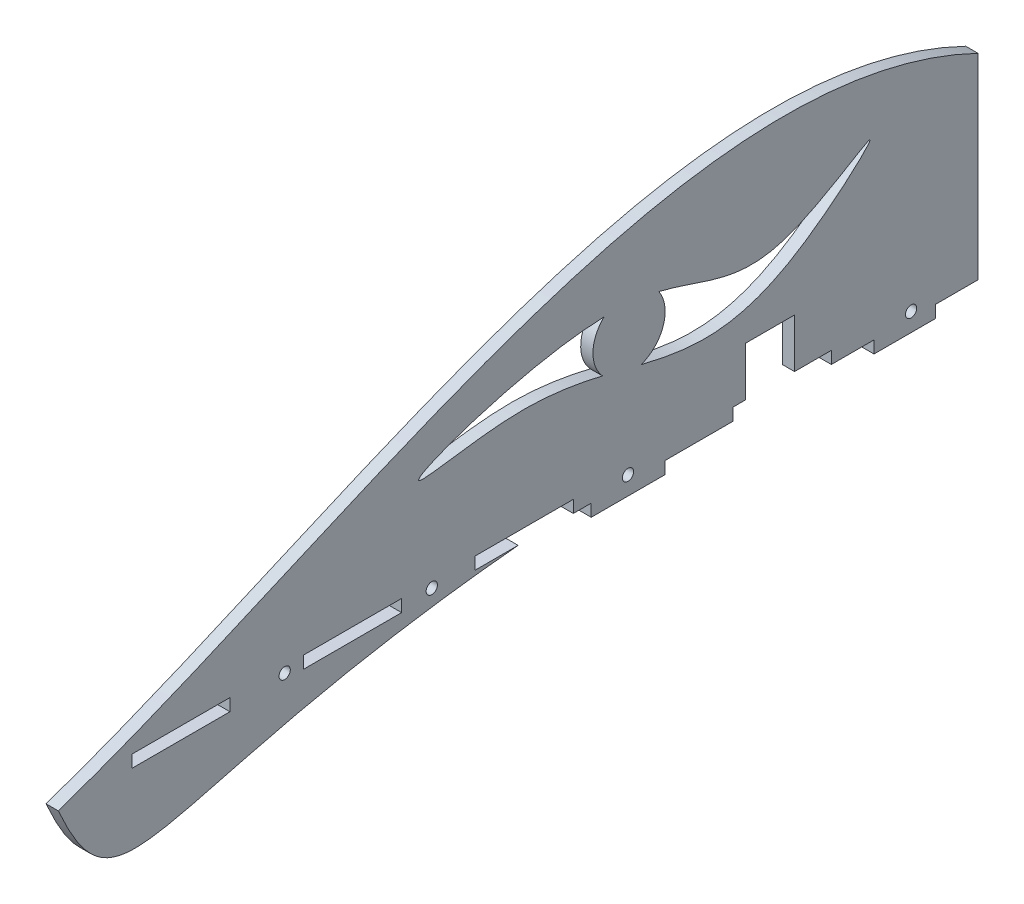
from build123d import *

# Parameters (mm, degrees)
BOSS_EXTRUDE1_DEPTH = 3.175
SKETCH2_R           = 1.4605
SKETCH2_W           = 25.4
SKETCH2_H           = 3.175
CUT_EXTRUDE1_DEPTH  = 6.35
BOSS_EXTRUDE3_DEPTH = 3.175
CUT_EXTRUDE2_DEPTH  = 3.175
SKETCH5_R           = 9.342587617
BOSS_EXTRUDE4_DEPTH = 3.175


with BuildPart() as part:
    # Sketch1 → Boss-Extrude1 (new body)
    with BuildSketch(Plane(origin=(0, 0, 0), x_dir=(0, 0, -1), z_dir=(1, 0, 0))):
        with BuildLine():
            Line((119.0625, 0), (238.125, 0))
            Line((238.125, 0), (238.125, 50.8))
            add(Edge.make_bspline(
                [(0, 0), (76.859833449, 26.070949446), (164.07477212, 86.623684005), (238.125, 50.8)],
                knots=[0, 0, 0, 0, 1, 1, 1, 1], degree=3))
            add(Edge.make_bspline(
                [(0, 0), (16.104921012, -36.272981342), (24.443498776, -9.039116005), (119.0625, 0)],
                knots=[0, 0, 0, 0, 1, 1, 1, 1], degree=3))
        make_face()
    extrude(amount=BOSS_EXTRUDE1_DEPTH)

    # Sketch2 → Cut-Extrude1 (cut)
    with BuildSketch(Plane(origin=(3.175, 0, 0), x_dir=(0, 0, -1), z_dir=(1, 0, 0))):
        Polygon((177.927, 15.875), (177.927, 3.175), (183.007, 3.175), (190.627, 3.175), (190.627, 15.875), (183.007, 15.875), align=None)
        Polygon((174.752, 3.175), (174.752, 0), (200.152, 0), (200.152, 3.175), (195.707, 3.175), (190.627, 3.175), (183.007, 3.175), (177.927, 3.175), align=None)
        with Locations((220.7895, 1.5875)):
            Circle(SKETCH2_R)
        Polygon((107.95, 3.175), (107.95, 0), (119.0625, 0), (133.35, 0), (133.35, 3.175), align=None)
        with Locations((76.2, 1.5875)):
            Rectangle(SKETCH2_W, SKETCH2_H)
        with Locations((31.75, 1.5875)):
            Rectangle(SKETCH2_W, SKETCH2_H)
        with Locations((58.6105, 1.5875)):
            Circle(SKETCH2_R)
        with Locations((147.5105, 1.5875)):
            Circle(SKETCH2_R)
        with Locations((96.7105, 1.5875)):
            Circle(SKETCH2_R)
    extrude(amount=-CUT_EXTRUDE1_DEPTH, mode=Mode.SUBTRACT)

    # Sketch3 → Boss-Extrude3 (add)
    with BuildSketch(Plane(origin=(3.175, 0, 0), x_dir=(0, 0, -1), z_dir=(1, 0, 0))):
        Polygon((137.98202267, -3.175), (137.98202267, 0), (137.98202267, 0.026209123), (157.03202267, 0.026209123), (157.03202267, 0), (157.03202267, -3.175), align=None)
        Polygon((211.201, -3.175), (227.076, -3.175), (227.076, 0), (227.076, 0.026209123), (208.026, 0.026209123), (211.201, 0), align=None)
    extrude(amount=-BOSS_EXTRUDE3_DEPTH)

    # Sketch4 → Cut-Extrude2 (cut)
    with BuildSketch(Plane(origin=(3.175, 0, 0), x_dir=(0, 0, -1), z_dir=(1, 0, 0))):
        with BuildLine():
            add(Edge.make_bspline(
                [(93.99664506, 27.196963526), (87.827491263, 27.713590543), (153.186488297, 52.129457971), (177.611392836, 22.94058013), (221.234059198, 54.380853992), (168.907937304, 6.387246602), (142.457192969, 36.658963722), (96.798574364, 26.962319938), (93.99664506, 27.196963526)],
                knots=[0, 0, 0, 0, 0.221914177, 0.399724301, 0.497137411, 0.601893931, 0.899210191, 1, 1, 1, 1], degree=3))
        make_face()
    extrude(amount=-CUT_EXTRUDE2_DEPTH, mode=Mode.SUBTRACT)

    # Sketch5 → Boss-Extrude4 (add)
    with BuildSketch(Plane(origin=(3.175, 0, 0), x_dir=(0, 0, -1), z_dir=(1, 0, 0))):
        with Locations((147.778068115, 33.398328751)):
            Circle(SKETCH5_R)
    extrude(amount=-BOSS_EXTRUDE4_DEPTH)


solid = part.part
